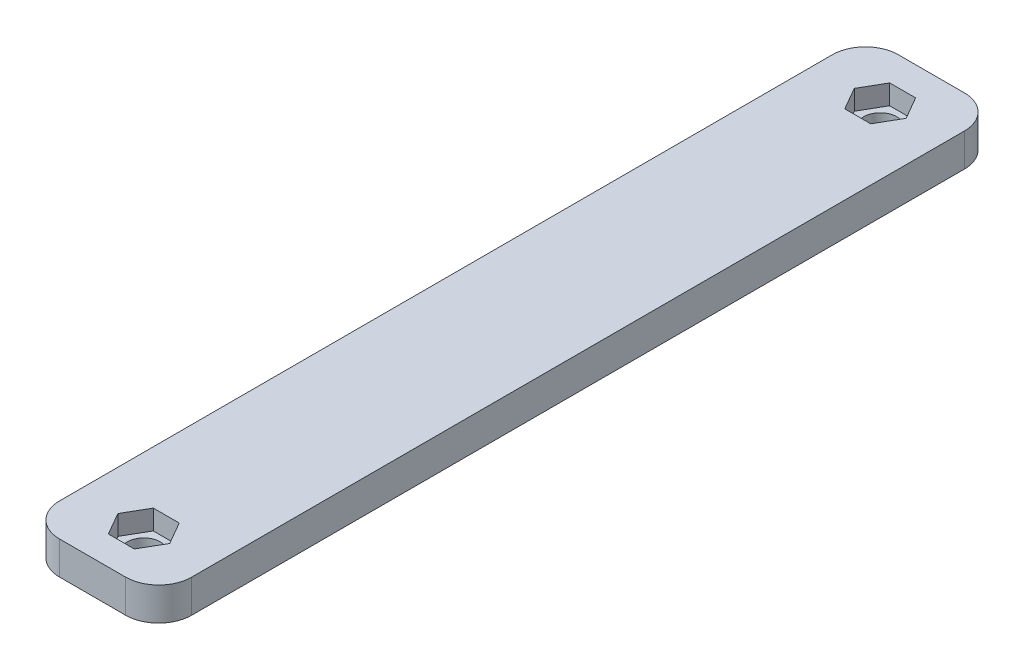
from build123d import *

# Parameters (mm, degrees)
SKETCH1_W           = 20
SKETCH1_H           = 127
BOSS_EXTRUDE1_DEPTH = 5
CUT_EXTRUDE1_DEPTH  = 3
SKETCH4_R           = 2.5
CUT_EXTRUDE2_DEPTH  = 3
FILLET1_R           = 5


with BuildPart() as part:
    # Sketch1 → Boss-Extrude1 (new body)
    with BuildSketch(Plane(origin=(0, 0, 0), x_dir=(1, 0, 0), z_dir=(0, 1, 0))):
        Rectangle(SKETCH1_W, SKETCH1_H)
    extrude(amount=BOSS_EXTRUDE1_DEPTH)

    # Sketch3 → Cut-Extrude1 (cut)
    with BuildSketch(Plane(origin=(0, 5, 0), x_dir=(1, 0, 0), z_dir=(0, 1, 0))):
        Polygon((3.92598183, 55.75), (1.962990915, 59.15), (-1.962990915, 59.15), (-3.92598183, 55.75), (-1.962990915, 52.35), (1.962990915, 52.35), align=None)
    cut_extrude1 = extrude(amount=-CUT_EXTRUDE1_DEPTH, mode=Mode.SUBTRACT)

    # Sketch4 → Cut-Extrude2 (cut, through all)
    with BuildSketch(Plane(origin=(0, 2, 0), x_dir=(1, 0, 0), z_dir=(0, 1, 0))):
        with Locations((0, 55.75)):
            Circle(SKETCH4_R)
    cut_extrude2 = extrude(amount=-CUT_EXTRUDE2_DEPTH, mode=Mode.SUBTRACT)

    # Mirror1: Cut-Extrude1, Cut-Extrude2 across plane
    add(cut_extrude1.mirror(Plane.XY), mode=Mode.SUBTRACT)
    add(cut_extrude2.mirror(Plane.XY), mode=Mode.SUBTRACT)

    # Fillet1
    fillet1_edges = [part.edges().sort_by_distance(p)[0] for p in [
        (10, 2.5, 63.5),
        (-10, 2.5, 63.5),
        (-10, 2.5, -63.5),
        (10, 2.5, -63.5),
    ]]
    fillet(fillet1_edges, radius=FILLET1_R)


solid = part.part
